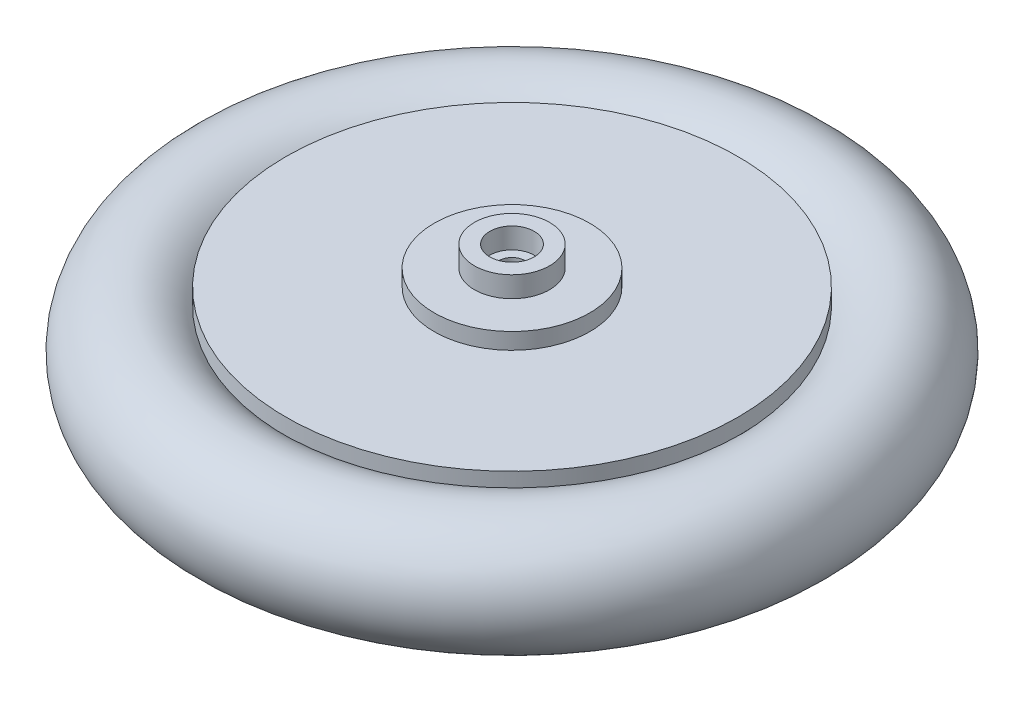
from build123d import *


with BuildPart() as part:
    # Esboço1 → Revolução1 (revolve)
    with BuildSketch(Plane.XY):
        with BuildLine():
            Line((30, -7.5), (30, -5.291502622))
            ThreePointArc((30, -5.291502622), (44, 0), (30, 5.291502622))
            Line((30, 5.291502622), (30, 7.5))
            Line((30, 7.5), (10, 7.5))
            Line((10, 7.5), (10, 9.7))
            Line((10, 9.7), (4.578419127, 9.7))
            Line((4.578419127, 9.7), (4.578419127, 12.5))
            Line((4.578419127, 12.5), (2.5, 12.5))
            Line((2.5, 12.5), (2.5, 9.7))
            Line((2.5, 9.7), (1.25, 9.7))
            Line((1.25, 9.7), (1.25, 7.5))
            Line((1.25, 7.5), (2.933342737, 7.5))
            Line((2.933342737, 7.5), (2.933342737, -7.5))
            Line((2.933342737, -7.5), (30, -7.5))
        make_face()
    revolve(axis=Axis((-0.5, 9.7, 0), (0, -1, 0)))


solid = part.part
